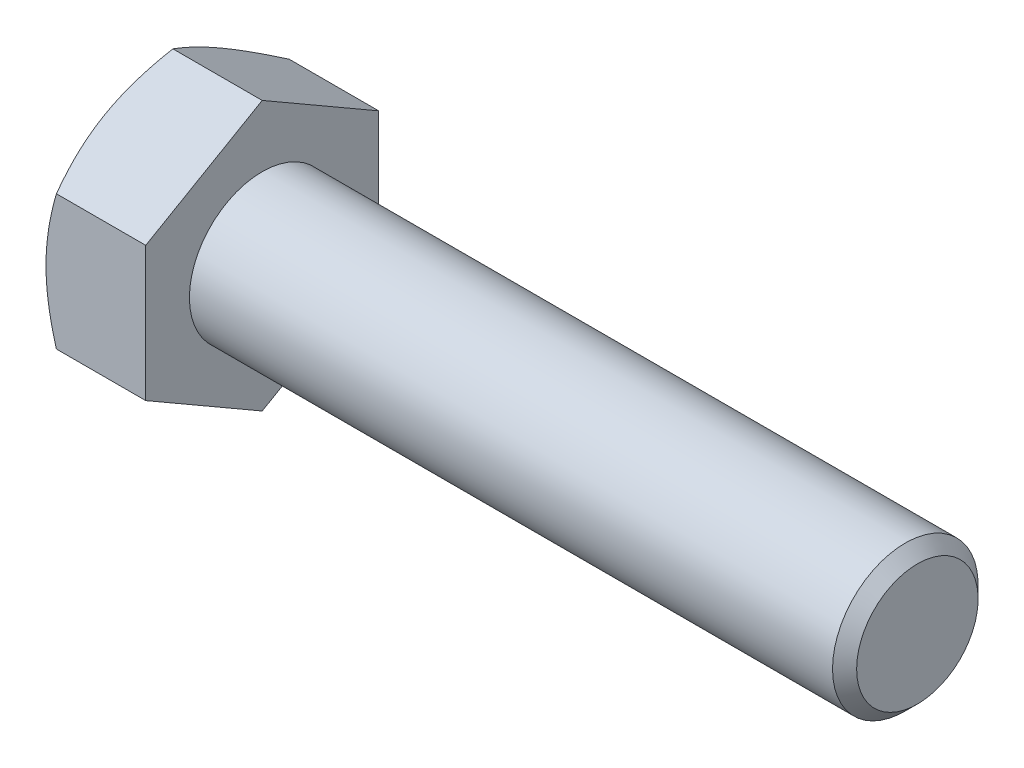
from build123d import *

# Parameters (mm, degrees)
BASEHEAD_DEPTH = 6.85


with BuildPart() as part:
    # Sketch1 → BaseHead (new body)
    with BuildSketch(Plane(origin=(0, 0, 0), x_dir=(0, 0, -1), z_dir=(1, 0, 0))):
        Polygon((8, 4.618802154), (8, -4.618802154), (0, -9.237604307), (-8, -4.618802154), (-8, 4.618802154), (0, 9.237604307), align=None)
    extrude(amount=BASEHEAD_DEPTH)

    # BodySke → BaseBody (revolve)
    with BuildSketch(Plane.XY):
        Polygon((0, 0), (51.85, 0), (51.85, 4.172), (51.022, 5), (0, 5), align=None)
    revolve(axis=Axis((0, 0, 0), (1, 0, 0)))

    # Sketch3 → HeadChamfer (revolve, cut)
    with BuildSketch(Plane.XY):
        Polygon((0, 8), (3.601282526, 14.237604307), (3.601282526, 19.237604307), (-10, 19.237604307), (-10, 8), align=None)
    revolve(axis=Axis((0, 0, 0), (1, 0, 0)), mode=Mode.SUBTRACT)


solid = part.part
